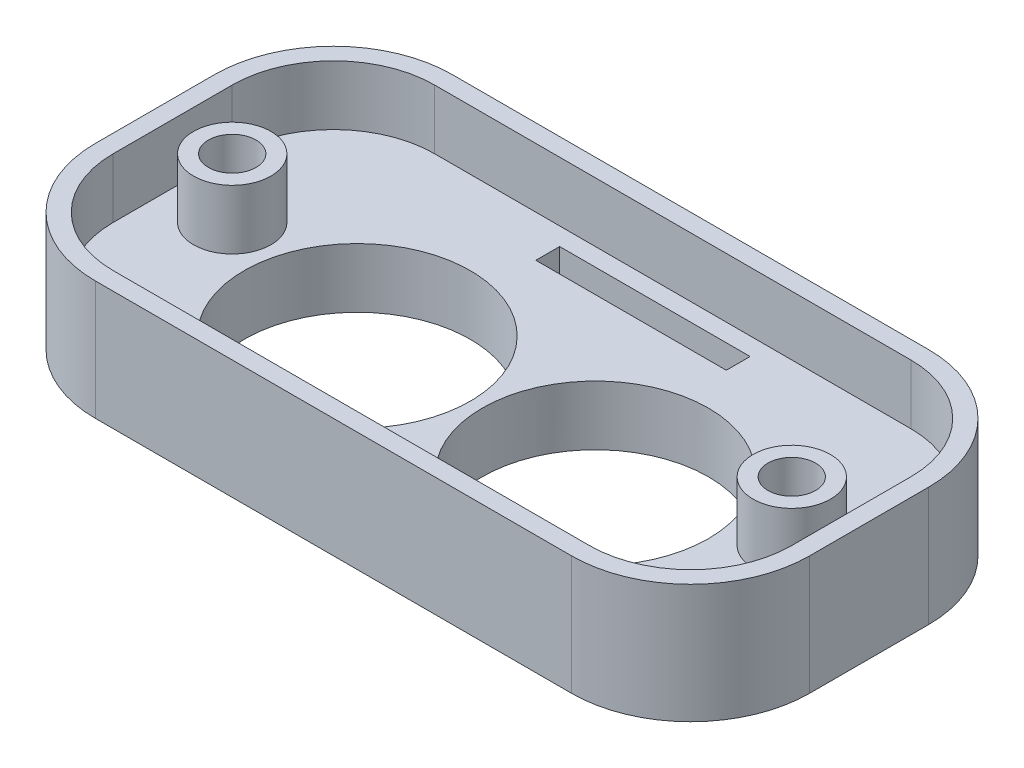
from build123d import *

# Parameters (mm, degrees)
SKETCH_1_R          = 9.5
EXTRUDE_1_DEPTH     = 10
SKETCH_2_R          = 8.5
SKETCH_2_R_2        = 9.5
CUT_EXTRUDE_1_DEPTH = 5
SKETCH_3_R          = 3.25
SKETCH_3_R_2        = 2
EXTRUDE_2_DEPTH     = 5
SKETCH_4_W          = 16
SKETCH_4_H          = 2
CUT_EXTRUDE_2_DEPTH = 6


with BuildPart() as part:
    # Эскиз1 → Бобышка-Вытянуть1 (new body)
    with BuildSketch(Plane(origin=(0, 0, 0), x_dir=(1, 0, 0), z_dir=(0, 1, 0))):
        with BuildLine():
            Line((-20, 18), (20, 18))
            ThreePointArc((20, 18), (27.071067812, 15.071067812), (30, 8))
            Line((30, 8), (30, -2))
            ThreePointArc((30, -2), (27.071067812, -9.071067812), (20, -12))
            Line((20, -12), (-20, -12))
            ThreePointArc((-20, -12), (-27.071067812, -9.071067812), (-30, -2))
            Line((-30, -2), (-30, 8))
            ThreePointArc((-30, 8), (-27.071067812, 15.071067812), (-20, 18))
        make_face()
        with Locations((-10, 0)):
            Circle(SKETCH_1_R, mode=Mode.SUBTRACT)
        with Locations((10, 0)):
            Circle(SKETCH_1_R, mode=Mode.SUBTRACT)
    extrude(amount=EXTRUDE_1_DEPTH)

    # Эскиз2 → Вырез-Вытянуть1 (cut)
    with BuildSketch(Plane(origin=(0, 10, 0), x_dir=(1, 0, 0), z_dir=(0, 1, 0))):
        with Locations((-20, -2)):
            Circle(SKETCH_2_R)
        with Locations((-20, 8)):
            Circle(SKETCH_2_R)
        with Locations((-10, 0)):
            Circle(SKETCH_2_R_2)
        with BuildLine():
            Line((20, 16.5), (-20, 16.5))
            ThreePointArc((-20, 16.5), (-14.492370575, 14.474258113), (-11.609926002, 9.362592497))
            ThreePointArc((-11.609926002, 9.362592497), (-3.878084328, 7.26444413), (-0.5, 0))
            ThreePointArc((-0.5, 0), (-5.086783087, -8.13082404), (-14.417957802, -8.410210988))
            ThreePointArc((-14.417957802, -8.410210988), (-17.01979811, -9.960426917), (-20, -10.5))
            Line((-20, -10.5), (20, -10.5))
            ThreePointArc((20, -10.5), (17.01979811, -9.960426917), (14.417957802, -8.410210988))
            ThreePointArc((14.417957802, -8.410210988), (0.616398255, -1.48257151), (11.609926002, 9.362592497))
            ThreePointArc((11.609926002, 9.362592497), (14.492370575, 14.474258113), (20, 16.5))
        make_face()
        with BuildLine():
            ThreePointArc((-26.873863542, 3), (-28.08324935, 5.371106707), (-28.5, 8))
            Line((-28.5, 8), (-28.5, -2))
            ThreePointArc((-28.5, -2), (-28.08324935, 0.628893293), (-26.873863542, 3))
        make_face()
        with Locations((20, -2)):
            Circle(SKETCH_2_R)
        with Locations((20, 8)):
            Circle(SKETCH_2_R)
        with Locations((10, 0)):
            Circle(SKETCH_2_R_2)
        with BuildLine():
            Line((28.5, -2), (28.5, 8))
            ThreePointArc((28.5, 8), (28.08324935, 5.371106707), (26.873863542, 3))
            ThreePointArc((26.873863542, 3), (28.08324935, 0.628893293), (28.5, -2))
        make_face()
    extrude(amount=-CUT_EXTRUDE_1_DEPTH, mode=Mode.SUBTRACT)

    # Эскиз3 → Бобышка-Вытянуть2 (add)
    with BuildSketch(Plane(origin=(0, 5, 0), x_dir=(1, 0, 0), z_dir=(0, 1, 0))):
        with Locations((-23.5, 3)):
            Circle(SKETCH_3_R)
        with Locations((-23.5, 3)):
            Circle(SKETCH_3_R_2, mode=Mode.SUBTRACT)
        with Locations((23.5, 3)):
            Circle(SKETCH_3_R)
        with Locations((23.5, 3)):
            Circle(SKETCH_3_R_2, mode=Mode.SUBTRACT)
    extrude(amount=EXTRUDE_2_DEPTH)

    # Эскиз4 → Вырез-Вытянуть2 (cut, through all)
    with BuildSketch(Plane(origin=(0, 5, 0), x_dir=(1, 0, 0), z_dir=(0, 1, 0))):
        with Locations((0, 14)):
            Rectangle(SKETCH_4_W, SKETCH_4_H)
    extrude(amount=-CUT_EXTRUDE_2_DEPTH, mode=Mode.SUBTRACT)


solid = part.part
